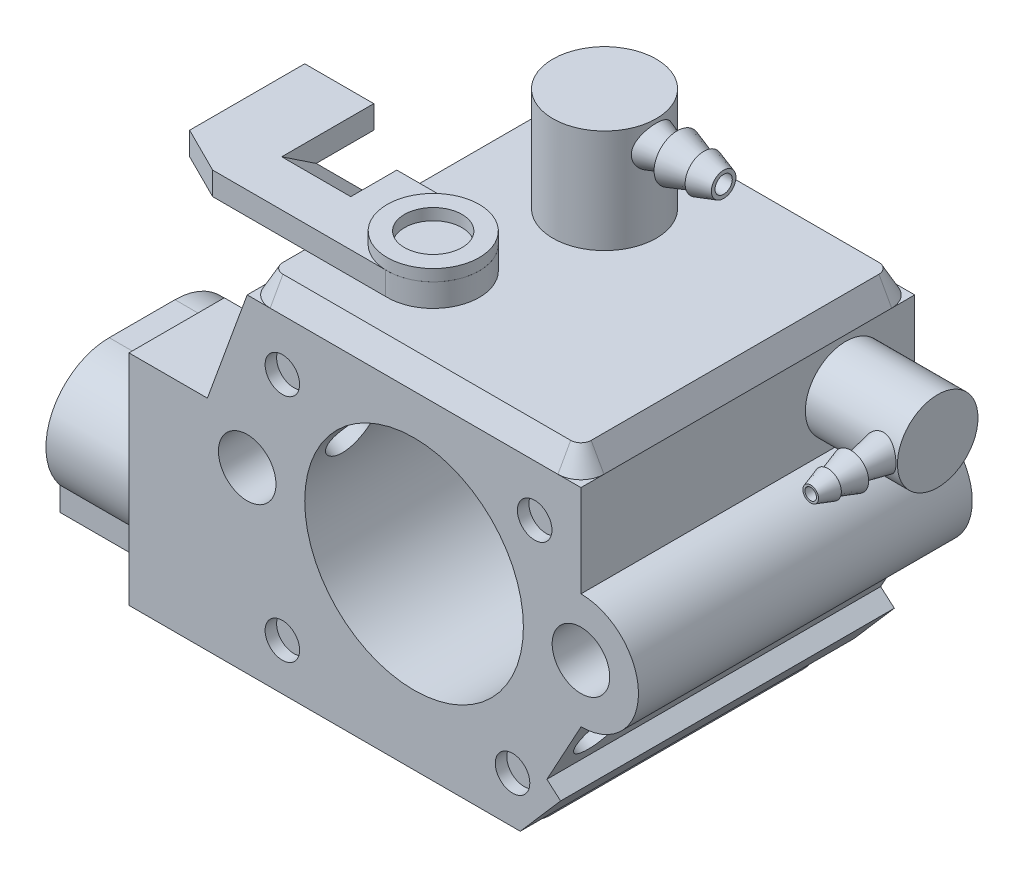
from build123d import *

# Parameters (mm, degrees)
SKETCH1_R            = 2.5
BOSS_EXTRUDE1_DEPTH  = 29
SKETCH2_R            = 9.5
CUT_EXTRUDE1_DEPTH   = 51.675326179
SKETCH2_6_R          = 9.5
SKETCH2_6_R_2        = 2.5
SKETCH2_6_R_3        = 1.5
CUT_EXTRUDE2_DEPTH   = 1
SKETCH6_R            = 2.5
SKETCH6_R_2          = 9.5
CUT_EXTRUDE3_DEPTH   = 51.109766347
SKETCH27_R           = 2
CUT_EXTRUDE7_DEPTH   = 65
BOSS_EXTRUDE2_DEPTH  = 10
CUT_EXTRUDE4_START   = -7
CUT_EXTRUDE4_DEPTH   = 7
BOSS_EXTRUDE3_DEPTH  = 1
SKETCH13_R           = 10.5
BOSS_EXTRUDE4_DEPTH  = 1.5
BOSS_EXTRUDE4_TAPER  = 36
SKETCH14_R           = 3.5
BOSS_EXTRUDE5_DEPTH  = 8
BOSS_EXTRUDE6_DEPTH  = 2
BOSS_EXTRUDE6_TAPER  = 29
SKETCH18_R           = 4.491355914
BOSS_EXTRUDE7_DEPTH  = 9
BOSS_EXTRUDE8_DEPTH  = 2
SKETCH20_R           = 4
SKETCH20_R_2         = 2.5
BOSS_EXTRUDE9_DEPTH  = 1
BOSS_EXTRUDE10_REACH = 66.468
SKETCH25_R           = 0.5
CUT_EXTRUDE5_DEPTH   = 9
SKETCH26_R           = 0.75
CUT_EXTRUDE6_DEPTH   = 9


with BuildPart() as part:
    # Sketch1 → Boss-Extrude1 (new body)
    with BuildSketch(Plane.XY):
        with BuildLine():
            Line((-14.028828829, 19), (-14.028828829, 0))
            Line((-14.028828829, 0), (19.971171171, 0))
            Line((19.971171171, 0), (23.476315099, 4.036089643))
            Line((23.476315099, 4.036089643), (22.286560603, 5.069332489))
            Line((22.286560603, 5.069332489), (25.250471061, 10.500003392))
            ThreePointArc((25.250471061, 10.500003392), (30.244646337, 15.502911939), (25.244647185, 20.5))
            Line((25.244647185, 20.5), (25.244647185, 28.5))
            Line((25.244647185, 28.5), (-3.755352815, 28.5))
            Line((-3.755352815, 28.5), (-7.213070041, 19))
            Line((-7.213070041, 19), (-14.028828829, 19))
        make_face()
        with Locations((25.244647185, 15.5)):
            Circle(SKETCH1_R, mode=Mode.SUBTRACT)
    extrude(amount=BOSS_EXTRUDE1_DEPTH)

    # Sketch2 → Cut-Extrude1 (cut, through all)
    with BuildSketch(Plane.XY.offset(29)):
        with Locations((10.744647185, 15.5)):
            Circle(SKETCH2_R)
    extrude(amount=-CUT_EXTRUDE1_DEPTH, mode=Mode.SUBTRACT)

    # Sketch2_6 → Cut-Extrude2 (cut)
    with BuildSketch(Plane.XY.offset(29)):
        with Locations((10.744647185, 15.5)):
            Circle(SKETCH2_6_R)
        with Locations((-3.755352815, 15.5)):
            Circle(SKETCH2_6_R_2)
        with Locations((21.22529921, 24.036089643)):
            Circle(SKETCH2_6_R_3)
        with Locations((-0.698224059, 24.036089643)):
            Circle(SKETCH2_6_R_3)
        with Locations((19.301775941, 4.036089643)):
            Circle(SKETCH2_6_R_3)
        with Locations((-0.698224059, 4.036089643)):
            Circle(SKETCH2_6_R_3)
    extrude(amount=-CUT_EXTRUDE2_DEPTH, mode=Mode.SUBTRACT)

    # Sketch6 → Cut-Extrude3 (cut, through all)
    with BuildSketch(Plane.XY.offset(28)):
        with Locations((-3.755352815, 15.5)):
            Circle(SKETCH6_R)
        with Locations((25.244647185, 15.5)):
            Circle(SKETCH6_R)
        with Locations((10.744647185, 15.5)):
            Circle(SKETCH6_R_2)
    extrude(amount=-CUT_EXTRUDE3_DEPTH, mode=Mode.SUBTRACT)

    # Sketch27 → Cut-Extrude7 (cut)
    with BuildSketch(Plane(origin=(15.039946678, -8.208388255, 0), x_dir=(0, 0, -1), z_dir=(0.8777782462028805, -0.479067166995397, 0))):
        with Locations((-26, 18.313346199)):
            Circle(SKETCH27_R)
        with Locations((-4, 18.313346199)):
            Circle(SKETCH27_R)
    extrude(amount=-CUT_EXTRUDE7_DEPTH, mode=Mode.SUBTRACT)

    # Sketch10 → Boss-Extrude2 (add)
    with BuildSketch(Plane.ZY.offset(14.028828829)):
        with BuildLine():
            Line((11, 0), (25, 0))
            Line((25, 0), (25, 2.052918349))
            ThreePointArc((25, 2.052918349), (25.674542678, 7.876031451), (20.714252914, 11))
            Line((20.714252914, 11), (15, 11))
            ThreePointArc((15, 11), (9.949651265, 7.678067412), (11, 1.725082782))
            Line((11, 1.725082782), (11, 0))
        make_face()
        with BuildLine():
            ThreePointArc((17.857126457, 3.478409436), (24.214252914, 5.5), (17.857126457, 7.521590564))
            ThreePointArc((17.857126457, 7.521590564), (11.5, 5.5), (17.857126457, 3.478409436))
        make_face(mode=Mode.SUBTRACT)
    extrude(amount=BOSS_EXTRUDE2_DEPTH)

    # Sketch11 → Cut-Extrude4 (cut)
    with BuildSketch(Plane.ZY.offset(14.028828829).offset(CUT_EXTRUDE4_START)):
        with BuildLine():
            Line((9.5, 5.5), (9.5, 19))
            Line((9.5, 19), (9.5, 20))
            Line((9.5, 20), (20.714252914, 20))
            Line((20.714252914, 20), (20.714252914, 19))
            Line((20.714252914, 19), (20.714252914, 11))
            Line((20.714252914, 11), (15, 11))
            ThreePointArc((15, 11), (11.110912703, 9.389087297), (9.5, 5.5))
        make_face()
    extrude(amount=CUT_EXTRUDE4_DEPTH, mode=Mode.SUBTRACT)

    # Sketch12 → Boss-Extrude3 (add)
    with BuildSketch(Plane.XZ):
        with BuildLine():
            Line((-5.928828829, 27.5), (17.071171171, 27.5))
            ThreePointArc((17.071171171, 27.5), (18.485384734, 26.914213562), (19.071171171, 25.5))
            Line((19.071171171, 25.5), (19.071171171, 3.5))
            ThreePointArc((19.071171171, 3.5), (18.485384734, 2.085786438), (17.071171171, 1.5))
            Line((17.071171171, 1.5), (-5.928828829, 1.5))
            ThreePointArc((-5.928828829, 1.5), (-7.343042391, 2.085786438), (-7.928828829, 3.5))
            Line((-7.928828829, 3.5), (-7.928828829, 25.5))
            ThreePointArc((-7.928828829, 25.5), (-7.343042391, 26.914213562), (-5.928828829, 27.5))
        make_face()
    extrude(amount=BOSS_EXTRUDE3_DEPTH)

    # Sketch13 → Boss-Extrude4 (add)
    with BuildSketch(Plane.XZ.offset(1)):
        with Locations((5.571171171, 14.5)):
            Circle(SKETCH13_R)
    extrude(amount=BOSS_EXTRUDE4_DEPTH, taper=BOSS_EXTRUDE4_TAPER)

    # Sketch14 → Boss-Extrude5 (add)
    with BuildSketch(Plane(origin=(25.244647185, 0, 0), x_dir=(0, 0, -1), z_dir=(1, 0, 0))):
        with Locations((-6, 24.5)):
            Circle(SKETCH14_R)
    extrude(amount=BOSS_EXTRUDE5_DEPTH)

    # Sketch16 → Revolve1 (revolve)
    with BuildSketch(Plane.ZX.offset(24.5)):
        Polygon((8.87886056, 33.244647185), (12, 32.59776031), (12, 33.244647185), (14, 32.59776031), (14, 32.871461105), (15.5, 32.386295949), (15.5, 31.707729006), (9.5, 31.707729006), (8.87886056, 31.707729006), align=None)
    revolve(axis=Axis((31.707729006, 24.5, 15.5), (0, 0, -1)))

    # Sketch17 → Boss-Extrude6 (add)
    with BuildSketch(Plane(origin=(0, 28.5, 0), x_dir=(1, 0, 0), z_dir=(0, 1, 0))):
        with BuildLine():
            Line((23.244647185, 0), (-1.755352815, 0))
            ThreePointArc((-1.755352815, 0), (-3.169566378, -0.585786438), (-3.755352815, -2))
            Line((-3.755352815, -2), (-3.755352815, -27))
            ThreePointArc((-3.755352815, -27), (-3.169566378, -28.414213562), (-1.755352815, -29))
            Line((-1.755352815, -29), (23.244647185, -29))
            ThreePointArc((23.244647185, -29), (24.658860747, -28.414213562), (25.244647185, -27))
            Line((25.244647185, -27), (25.244647185, -2))
            ThreePointArc((25.244647185, -2), (24.658860747, -0.585786438), (23.244647185, 0))
        make_face()
    extrude(amount=BOSS_EXTRUDE6_DEPTH, taper=BOSS_EXTRUDE6_TAPER)

    # Sketch18 → Boss-Extrude7 (add)
    with BuildSketch(Plane(origin=(0, 30.5, 0), x_dir=(1, 0, 0), z_dir=(0, 1, 0))):
        with Locations((7.267412162, -8.971106597)):
            Circle(SKETCH18_R)
    extrude(amount=BOSS_EXTRUDE7_DEPTH)

    # Sketch19 → Boss-Extrude8 (add)
    with BuildSketch(Plane(origin=(0, 30.5, 0), x_dir=(1, 0, 0), z_dir=(0, 1, 0))):
        with BuildLine():
            Line((-10.646734712, -25.108618103), (-14.646734712, -23.108618103))
            Line((-14.646734712, -23.108618103), (-14.646734712, -13.108618103))
            Line((-14.646734712, -13.108618103), (-8.646734712, -13.108618103))
            Line((-8.646734712, -13.108618103), (-8.646734712, -23.108618103))
            Line((-8.646734712, -23.108618103), (-2.646734712, -23.108618103))
            Line((-2.646734712, -23.108618103), (-2.646734712, -17.108618103))
            Line((-2.646734712, -17.108618103), (4.687209994, -17.108618103))
            ThreePointArc((4.687209994, -17.108618103), (8.520237641, -21.275590456), (4.353265288, -25.108618103))
            Line((4.353265288, -25.108618103), (-2.646734712, -25.108618103))
            Line((-2.646734712, -25.108618103), (-10.646734712, -25.108618103))
        make_face()
    extrude(amount=BOSS_EXTRUDE8_DEPTH)

    # Sketch20 → Boss-Extrude9 (add)
    with BuildSketch(Plane(origin=(0, 32.5, 0), x_dir=(1, 0, 0), z_dir=(0, 1, 0))):
        with Locations((4.520237641, -21.108618103)):
            Circle(SKETCH20_R)
        with Locations((4.520237641, -21.108618103)):
            Circle(SKETCH20_R_2, mode=Mode.SUBTRACT)
    extrude(amount=BOSS_EXTRUDE9_DEPTH)

    # Sketch22 → Revolve2 (revolve)
    with BuildSketch(Plane(origin=(0, 0, 8.971106597), x_dir=(-1, 0, 0), z_dir=(0, 0, -1))):
        Polygon((-17.615312055, 37.490470155), (-10.736326453, 37.490470155), (-10.736326453, 39.5), (-13.578550719, 38.558914033), (-13.578550719, 39.5), (-15.893217754, 38.733592967), (-15.893217754, 39.116796484), (-17.615312055, 38.558914033), align=None)
    revolve(axis=Axis((17.615312055, 37.490470155, 8.971106597), (-1, 0, 0)))

    # Sketch24 → Boss-Extrude10 (add, up to next)
    with BuildSketch(Plane(origin=(-8.646734712, 0, 0), x_dir=(0, 0, -1), z_dir=(1, 0, 0)), mode=Mode.PRIVATE) as boss_extrude10_sk1:
        Polygon((-21.108618103, 32.5), (-18.108618103, 30.5), (-23.108618103, 30.5), (-23.108618103, 32.5), align=None)
    boss_extrude10_tool1 = extrude(boss_extrude10_sk1.sketch, amount=BOSS_EXTRUDE10_REACH, mode=Mode.PRIVATE) - part.part
    add(boss_extrude10_tool1.solids().sort_by_distance((-8.646735, 31.357143, 21.251475))[0])

    # Sketch25 → Cut-Extrude5 (cut)
    with BuildSketch(Plane.XY.offset(15.5)):
        with Locations((31.707729006, 24.5)):
            Circle(SKETCH25_R)
    extrude(amount=-CUT_EXTRUDE5_DEPTH, mode=Mode.SUBTRACT)

    # Sketch26 → Cut-Extrude6 (cut)
    with BuildSketch(Plane(origin=(17.615312055, 0, 0), x_dir=(0, 0, -1), z_dir=(1, 0, 0))):
        with Locations((-8.971106597, 37.490470155)):
            Circle(SKETCH26_R)
    extrude(amount=-CUT_EXTRUDE6_DEPTH, mode=Mode.SUBTRACT)


solid = part.part
